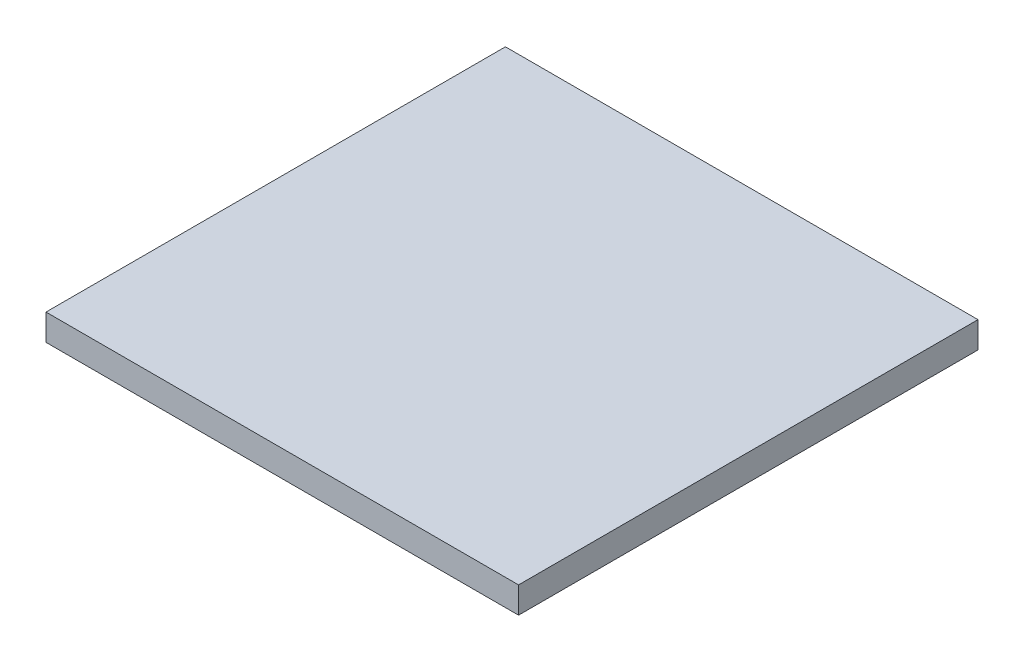
from build123d import *

# Parameters (mm, degrees)
SKETCH1_W           = 36
SKETCH1_H           = 35
BOSS_EXTRUDE1_DEPTH = 2


with BuildPart() as part:
    # Sketch1 → Boss-Extrude1 (new body)
    with BuildSketch(Plane(origin=(0, 0, 0), x_dir=(1, 0, 0), z_dir=(0, 1, 0))):
        with Locations((18, -17.5)):
            Rectangle(SKETCH1_W, SKETCH1_H)
    extrude(amount=BOSS_EXTRUDE1_DEPTH)


solid = part.part
